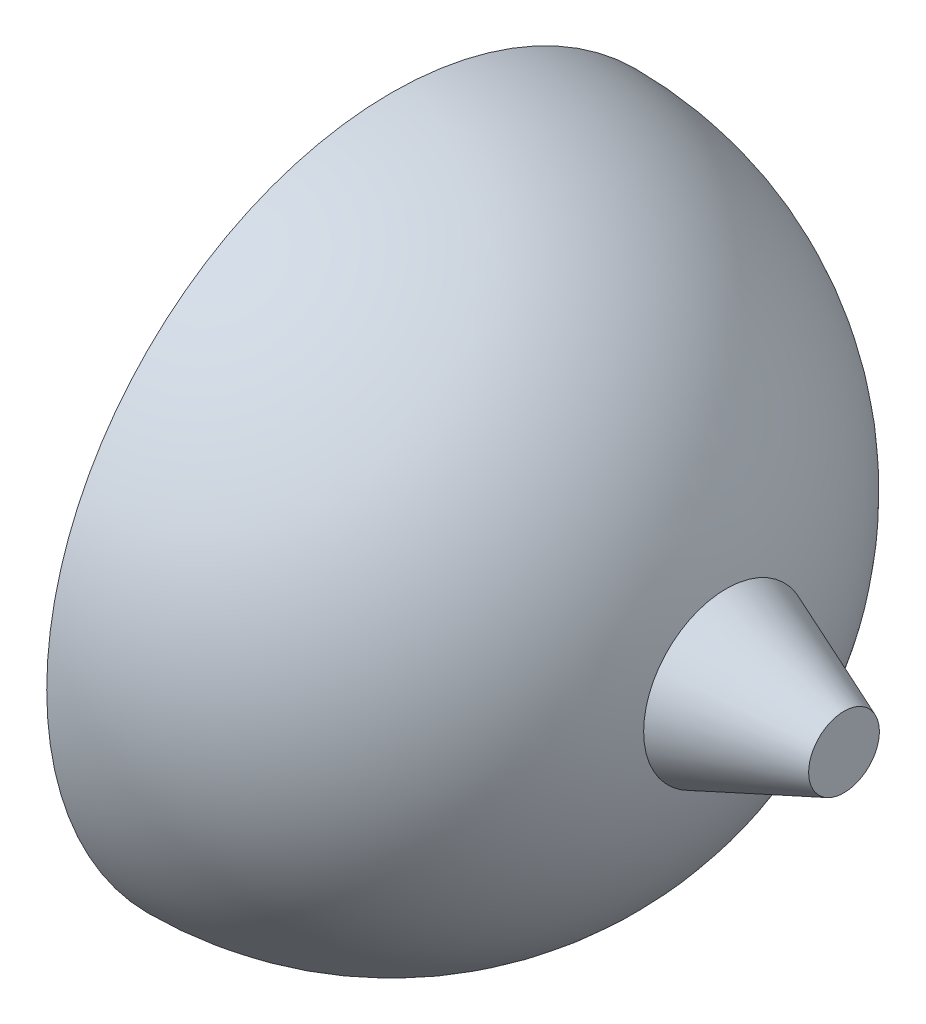
from build123d import *


with BuildPart() as part:
    # Sketch2 → Revolve2 (revolve)
    with BuildSketch(Plane(origin=(0, 0, 0), x_dir=(1, 0, 0), z_dir=(0, 1, 0))):
        with BuildLine():
            Line((0, 2.925), (0, 0.7))
            Line((0, 0.7), (-1, 0.3))
            Line((-1, 0.3), (-1, 0))
            Line((-1, 0), (0, 0))
            Line((0, 0), (2.925, 0))
            ThreePointArc((2.925, 0), (2.068287335, 2.068287335), (0, 2.925))
        make_face()
    revolve(axis=Axis((0, 0, 0), (1, 0, 0)))

    # Sketch3 → Revolve3 (revolve)
    with BuildSketch(Plane.XY):
        Polygon((2.925, 0), (3.840004401, 0), (3.840004401, 0.3), (2.840004401, 0.7), align=None)
    revolve(axis=Axis((2.925, 0, 0), (1, 0, 0)))


solid = part.part
